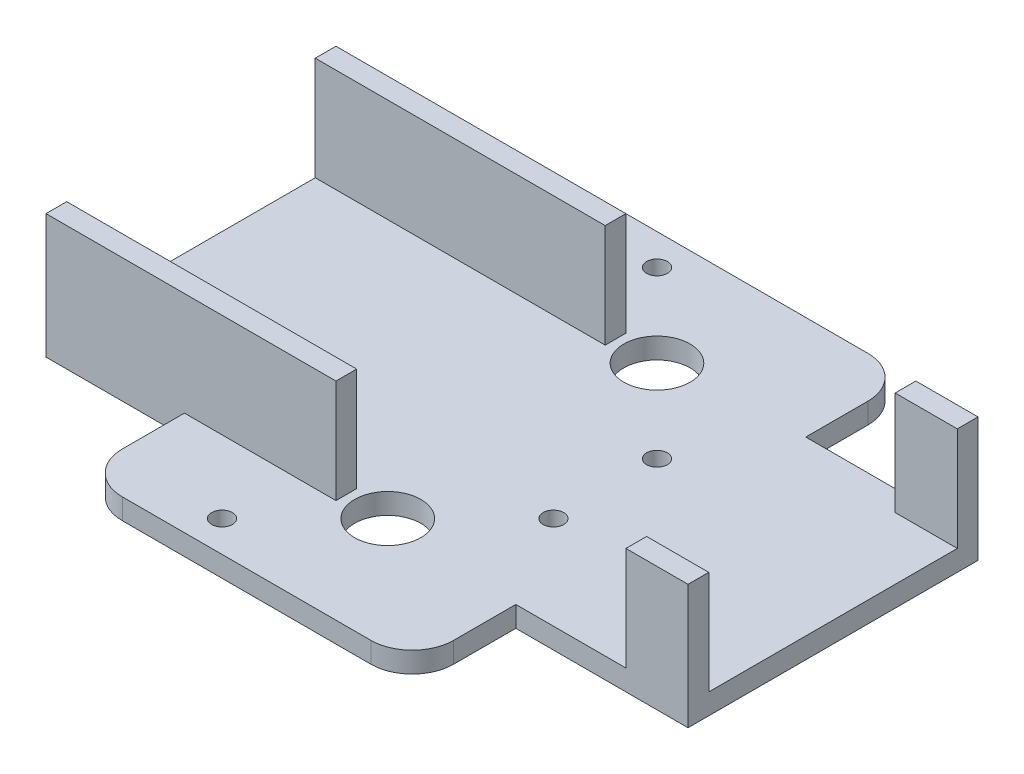
from build123d import *

# Parameters (mm, degrees)
SKETCH1_W           = 155
SKETCH1_H           = 70
BOSS_EXTRUDE1_DEPTH = 30
SKETCH2_W           = 70
SKETCH2_H           = 25
CUT_EXTRUDE1_DEPTH  = 71
SKETCH5_W           = 60
SKETCH5_H           = 25
CUT_EXTRUDE2_DEPTH  = 156
SKETCH6_W           = 80
SKETCH6_H           = 25
BOSS_EXTRUDE2_DEPTH = 5
SKETCH8_R           = 8
SKETCH8_R_2         = 2.5
CUT_EXTRUDE4_DEPTH  = 6
FILLET5_R           = 10
FILLET6_R           = 10


with BuildPart() as part:
    # Sketch1 → Boss-Extrude1 (new body)
    with BuildSketch(Plane(origin=(0, 0, 0), x_dir=(1, 0, 0), z_dir=(0, 1, 0))):
        with Locations((2.5, 0)):
            Rectangle(SKETCH1_W, SKETCH1_H)
    extrude(amount=BOSS_EXTRUDE1_DEPTH)

    # Sketch2 → Cut-Extrude1 (cut, through all)
    with BuildSketch(Plane.XY.offset(35)):
        with Locations((30, 17.5)):
            Rectangle(SKETCH2_W, SKETCH2_H)
    extrude(amount=-CUT_EXTRUDE1_DEPTH, mode=Mode.SUBTRACT)

    # Sketch5 → Cut-Extrude2 (cut, through all)
    with BuildSketch(Plane(origin=(80, 0, 0), x_dir=(0, 0, -1), z_dir=(1, 0, 0))):
        with Locations((0, 17.5)):
            Rectangle(SKETCH5_W, SKETCH5_H)
    extrude(amount=-CUT_EXTRUDE2_DEPTH, mode=Mode.SUBTRACT)

    # Sketch6 → Boss-Extrude2 (add)
    with BuildSketch(Plane(origin=(0, 0, 0), x_dir=(1, 0, 0), z_dir=(0, 1, 0))):
        with Locations((-1.578945933, -47.5)):
            Rectangle(SKETCH6_W, SKETCH6_H)
        with Locations((-1.578945933, 47.5)):
            Rectangle(SKETCH6_W, SKETCH6_H)
    extrude(amount=BOSS_EXTRUDE2_DEPTH)

    # Sketch8 → Cut-Extrude4 (cut, through all)
    with BuildSketch(Plane(origin=(0, 5, 0), x_dir=(1, 0, 0), z_dir=(0, 1, 0))):
        with Locations((5, 32.5)):
            Circle(SKETCH8_R)
        with Locations((5, -32.5)):
            Circle(SKETCH8_R)
        with Locations((-15, 52.5)):
            Circle(SKETCH8_R_2)
        with Locations((25, 12.5)):
            Circle(SKETCH8_R_2)
        with Locations((-15, -52.5)):
            Circle(SKETCH8_R_2)
        with Locations((25, -12.5)):
            Circle(SKETCH8_R_2)
    extrude(amount=-CUT_EXTRUDE4_DEPTH, mode=Mode.SUBTRACT)

    # Fillet5
    fillet5_edges = [part.edges().sort_by_distance(p)[0] for p in [
        (38.421054067, 2.5, 60),
    ]]
    fillet(fillet5_edges, radius=FILLET5_R)

    # Fillet6
    fillet6_edges = [part.edges().sort_by_distance(p)[0] for p in [
        (-41.578945933, 2.5, -60),
        (38.421054067, 2.5, -60),
        (-41.578945933, 2.5, 60),
    ]]
    fillet(fillet6_edges, radius=FILLET6_R)


solid = part.part
